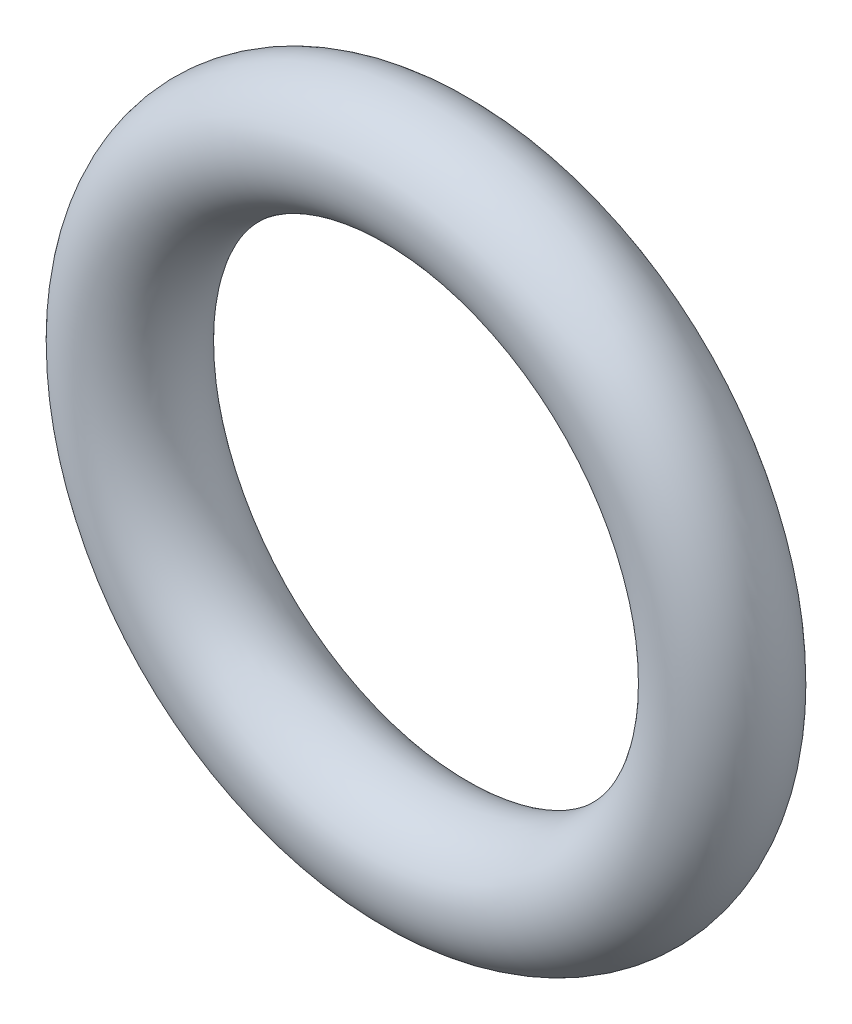
from build123d import *

# Parameters (mm, degrees)
SKETCH1_R = 2


with BuildPart() as part:
    # Sketch1 → Revolve1 (revolve)
    with BuildSketch(Plane(origin=(0, 0, 0), x_dir=(0, -1, 0), z_dir=(1, 0, 0))):
        with Locations((10, 0)):
            Circle(SKETCH1_R)
    revolve(axis=Axis((0, 0, 2), (0, 0, -1)))


solid = part.part
